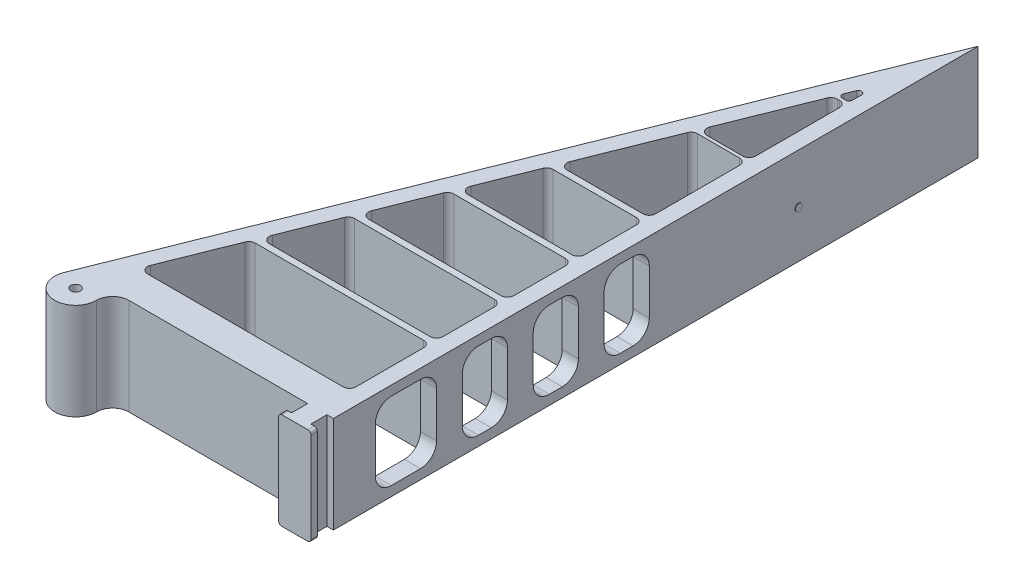
from build123d import *

# Parameters (mm, degrees)
BOSS_EXTRUDE1_DEPTH = 30
BOSS_EXTRUDE2_DEPTH = 30
SKETCH3_R           = 1.5
BOSS_EXTRUDE3_DEPTH = 30
SKETCH4_R           = 1.100328426
BOSS_EXTRUDE4_DEPTH = 0.1
SKETCH5_W           = 14
SKETCH5_H           = 24
SKETCH5_W_2         = 19
CUT_EXTRUDE1_DEPTH  = 6.1
FILLET1_R           = 2
FILLET2_R           = 1
FILLET3_R           = 5
FILLET4_R           = 1


with BuildPart() as part:
    # Sketch1 → Boss-Extrude1 (new body)
    with BuildSketch(Plane(origin=(0, 0, 0), x_dir=(1, 0, 0), z_dir=(0, 1, 0))):
        Polygon((0, 0), (-80, 0), (0, 200), align=None)
        Polygon((-5, 10), (-70.614835193, 10), (-5, 174.037087982), align=None, mode=Mode.SUBTRACT)
    extrude(amount=BOSS_EXTRUDE1_DEPTH)

    # Sketch2 → Boss-Extrude2 (add)
    with BuildSketch(Plane(origin=(0, 0, 0), x_dir=(1, 0, 0), z_dir=(0, 1, 0))):
        Polygon((-5, 35), (-60.614835193, 35), (-59.814835193, 37), (-5, 37), align=None)
        Polygon((-51.014835193, 59), (-51.814835193, 57), (-5, 57), (-5, 59), align=None)
        Polygon((-43.014835193, 79), (-5, 79), (-5, 81), (-42.214835193, 81), align=None)
        Polygon((-34.214835193, 101), (-33.414835193, 103), (-5, 103), (-5, 101), align=None)
        Polygon((-21.414835193, 133), (-21.014835193, 134), (-5, 134), (-5, 133), align=None)
        Polygon((-9.014835193, 164), (-8.614835193, 165), (-5, 165), (-5, 164), align=None)
    extrude(amount=BOSS_EXTRUDE2_DEPTH)

    # Sketch3 → Boss-Extrude3 (add)
    with BuildSketch(Plane(origin=(0, 0, 0), x_dir=(1, 0, 0), z_dir=(0, 1, 0))):
        Polygon((-2, 0), (-2, -5), (0, -5), (0, -7), (-10, -7), (-10, -5), (-8, -5), (-8, 0), align=None)
        with BuildLine():
            Line((-80, 0), (-81.034384241, -2.585960604))
            ThreePointArc((-81.034384241, -2.585960604), (-76.228484638, -11.382716514), (-68.499285751, -5))
            ThreePointArc((-68.499285751, -5), (-67.034819657, -1.464466094), (-63.499285751, 0))
            Line((-63.499285751, 0), (-80, 0))
        make_face()
        with Locations((-74.999285751, -5)):
            Circle(SKETCH3_R, mode=Mode.SUBTRACT)
    extrude(amount=BOSS_EXTRUDE3_DEPTH)

    # Sketch4 → Boss-Extrude4 (add)
    with BuildSketch(Plane(origin=(0, 0, 0), x_dir=(0, 0, -1), z_dir=(1, 0, 0))):
        with Locations((144.319162345, 14.586186638)):
            Circle(SKETCH4_R)
    extrude(amount=BOSS_EXTRUDE4_DEPTH)

    # Sketch5 → Cut-Extrude1 (cut, through all)
    with BuildSketch(Plane.ZY.offset(5)):
        with Locations((-91, 15)):
            Rectangle(SKETCH5_W, SKETCH5_H)
        with Locations((-69, 15)):
            Rectangle(SKETCH5_W, SKETCH5_H)
        with Locations((-47, 15)):
            Rectangle(SKETCH5_W, SKETCH5_H)
        with Locations((-22.5, 15)):
            Rectangle(SKETCH5_W_2, SKETCH5_H)
    extrude(amount=-CUT_EXTRUDE1_DEPTH, mode=Mode.SUBTRACT)

    # Fillet1
    fillet1_edges = [part.edges().sort_by_distance(p)[0] for p in [
        (-5, 15, -10),
        (-70.614835193, 15, -10),
        (-60.614835193, 15, -35),
        (-59.814835193, 15, -37),
        (-5, 15, -37),
        (-5, 15, -35),
        (-5, 15, -57),
        (-51.814835193, 15, -57),
        (-51.014835193, 15, -59),
        (-5, 15, -59),
        (-5, 15, -81),
        (-5, 15, -79),
        (-43.014835193, 15, -79),
        (-42.214835193, 15, -81),
        (-33.414835193, 15, -103),
        (-5, 15, -103),
        (-5, 15, -101),
        (-34.214835193, 15, -101),
        (-21.014835193, 15, -134),
        (-5, 15, -134),
        (-5, 15, -133),
        (-21.414835193, 15, -133),
        (-5, 15, -164),
        (-9.014835193, 15, -164),
    ]]
    fillet(fillet1_edges, radius=FILLET1_R)

    # Fillet2
    fillet2_edges = [part.edges().sort_by_distance(p)[0] for p in [
        (-5, 15, -174.037087982),
        (-8.614835193, 15, -165),
        (-5, 15, -165),
    ]]
    fillet(fillet2_edges, radius=FILLET2_R)

    # Fillet3
    fillet3_edges = [part.edges().sort_by_distance(p)[0] for p in [
        (-2.5, 27, -84),
        (-2.5, 3, -84),
        (-2.5, 3, -98),
        (-2.5, 27, -98),
        (-2.5, 27, -62),
        (-2.5, 3, -62),
        (-2.5, 3, -76),
        (-2.5, 27, -76),
        (-2.5, 27, -40),
        (-2.5, 3, -40),
        (-2.5, 3, -54),
        (-2.5, 27, -54),
        (-2.5, 27, -13),
        (-2.5, 3, -13),
        (-2.5, 3, -32),
        (-2.5, 27, -32),
    ]]
    fillet(fillet3_edges, radius=FILLET3_R)

    # Fillet4
    fillet4_edges = [part.edges().sort_by_distance(p)[0] for p in [
        (0, 30, 6),
        (0, 0, 6),
        (-10, 30, 6),
        (-10, 0, 6),
    ]]
    fillet(fillet4_edges, radius=FILLET4_R)


solid = part.part
